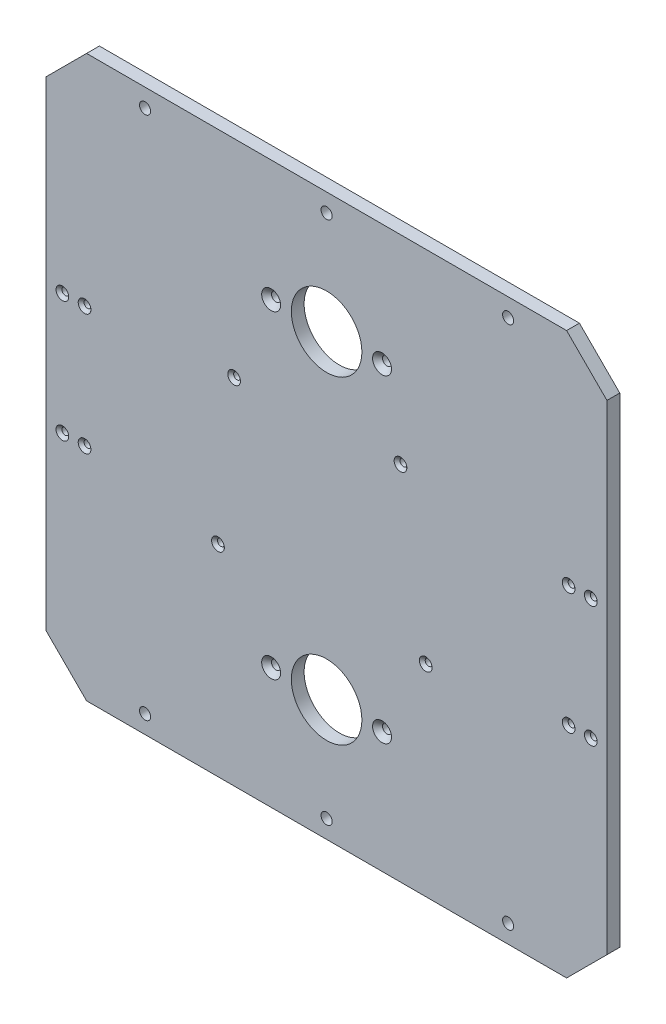
from build123d import *

# Parameters (mm, degrees)
SKETCH1_W                                       = 278
SKETCH1_H                                       = 278
BOSS_EXTRUDE1_DEPTH                             = 6.35
CHAMFER1_SIZE                                   = 20
SKETCH4_R                                       = 2.75
CUT_EXTRUDE2_DEPTH                              = 76.2
SKETCH8_R                                       = 17.5
CUT_EXTRUDE4_DEPTH                              = 105
CSK_FOR_M4_FLAT_HEAD_MACHINE_SCREW2_D           = 4.5
CSK_FOR_M4_FLAT_HEAD_MACHINE_SCREW2_CSINK_D     = 9.4
CSK_FOR_M4_FLAT_HEAD_MACHINE_SCREW2_CSINK_ANGLE = 90
CSK_FOR_M3_FLAT_HEAD_MACHINE_SCREW1_D           = 3.4
CSK_FOR_M3_FLAT_HEAD_MACHINE_SCREW1_CSINK_D     = 6.3
CSK_FOR_M3_FLAT_HEAD_MACHINE_SCREW1_CSINK_ANGLE = 90
CSK_FOR_M3_FLAT_HEAD_MACHINE_SCREW2_D           = 3.4
CSK_FOR_M3_FLAT_HEAD_MACHINE_SCREW2_CSINK_D     = 6.3
CSK_FOR_M3_FLAT_HEAD_MACHINE_SCREW2_CSINK_ANGLE = 90


with BuildPart() as part:
    # Sketch1 → Boss-Extrude1 (new body)
    with BuildSketch(Plane.XY):
        Rectangle(SKETCH1_W, SKETCH1_H)
    extrude(amount=BOSS_EXTRUDE1_DEPTH)

    # Chamfer1
    chamfer1_edges = [part.edges().sort_by_distance(p)[0] for p in [
        (-139, 139, 3.175),
        (139, 139, 3.175),
        (139, -139, 3.175),
        (-139, -139, 3.175),
    ]]
    chamfer(chamfer1_edges, length=CHAMFER1_SIZE)

    # Sketch4 → Cut-Extrude2 (cut)
    with BuildSketch(Plane.XY.offset(6.35)):
        with Locations((-90, 130)):
            Circle(SKETCH4_R)
        with Locations((0, 130)):
            Circle(SKETCH4_R)
        with Locations((90, 130)):
            Circle(SKETCH4_R)
        with Locations((90, -130)):
            Circle(SKETCH4_R)
        with Locations((0, -130)):
            Circle(SKETCH4_R)
        with Locations((-90, -130)):
            Circle(SKETCH4_R)
    extrude(amount=-CUT_EXTRUDE2_DEPTH, mode=Mode.SUBTRACT)

    # Sketch8 → Cut-Extrude4 (cut)
    with BuildSketch(Plane.XY.offset(6.35)):
        with Locations((0, 79)):
            Circle(SKETCH8_R)
        with Locations((0, -79)):
            Circle(SKETCH8_R)
    extrude(amount=-CUT_EXTRUDE4_DEPTH, mode=Mode.SUBTRACT)

    # CSK for M4 Flat Head Machine Screw2 (through all)
    with Locations(Plane.XY.offset(6.35)):
        with Locations((27.5, 79), (-27.5, 79), (-27.5, -79), (27.5, -79)):
            CounterSinkHole(CSK_FOR_M4_FLAT_HEAD_MACHINE_SCREW2_D / 2, CSK_FOR_M4_FLAT_HEAD_MACHINE_SCREW2_CSINK_D / 2, counter_sink_angle=CSK_FOR_M4_FLAT_HEAD_MACHINE_SCREW2_CSINK_ANGLE)

    # CSK for M3 Flat Head Machine Screw1 (through all)
    with Locations(Plane.XY.offset(6.35)):
        with Locations((-131, 30), (-120, 30), (-120, -30), (-131, -30), (131, -30), (120, -30), (120, 30), (131, 30)):
            CounterSinkHole(CSK_FOR_M3_FLAT_HEAD_MACHINE_SCREW1_D / 2, CSK_FOR_M3_FLAT_HEAD_MACHINE_SCREW1_CSINK_D / 2, counter_sink_angle=CSK_FOR_M3_FLAT_HEAD_MACHINE_SCREW1_CSINK_ANGLE)

    # CSK for M3 Flat Head Machine Screw2 (through all)
    with Locations(Plane.XY.offset(6.35)):
        with Locations((-45.858494434, 36.37268476), (-53.858494434, -39.12731524), (36.641505566, 40.37268476), (49.141505566, -39.12731524)):
            CounterSinkHole(CSK_FOR_M3_FLAT_HEAD_MACHINE_SCREW2_D / 2, CSK_FOR_M3_FLAT_HEAD_MACHINE_SCREW2_CSINK_D / 2, counter_sink_angle=CSK_FOR_M3_FLAT_HEAD_MACHINE_SCREW2_CSINK_ANGLE)


solid = part.part
